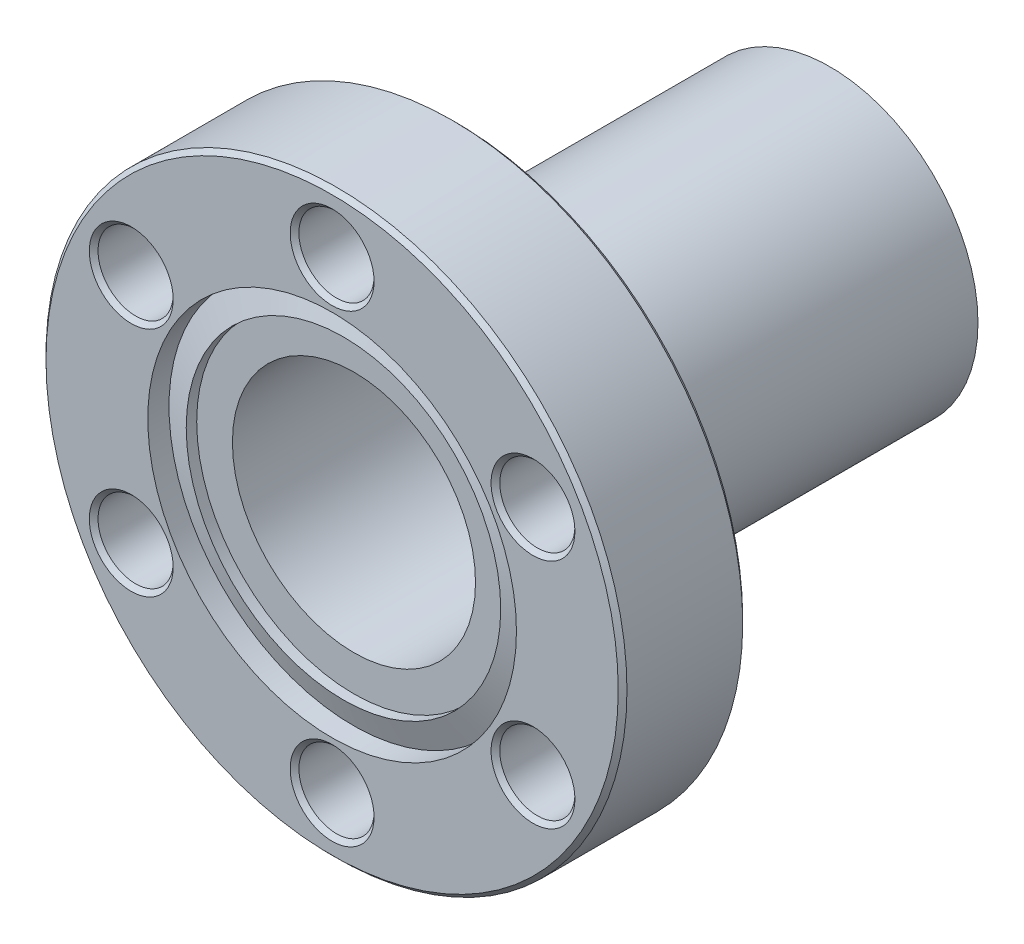
from build123d import *

# Parameters (mm, degrees)
M8_CLEARANCE_HOLE1_D     = 9.5758
M8_CLEARANCE_HOLE1_DEPTH = 7.239
M4_CLEARANCE_HOLE1_D     = 4.3688
M4_CLEARANCE_HOLE1_DEPTH = 7.239
M4_CLEARANCE_HOLE2_D     = 4.3688
M4_CLEARANCE_HOLE2_DEPTH = 7.239
CHAMFER1_SIZE            = 0.254
SKETCH8_R                = 8.600554372
BOSS_EXTRUDE1_DEPTH      = 21.717
SKETCH9_R                = 7.068084354
CUT_EXTRUDE1_DEPTH       = 29.956


with BuildPart() as part:
    # Sketch1 → Revolve1 (revolve)
    with BuildSketch(Plane(origin=(0, 0, 0), x_dir=(1, 0, 0), z_dir=(0, 1, 0))):
        with BuildLine():
            Line((16.891, 7.239), (0, 7.239))
            Line((0, 7.239), (0, 1.27))
            Line((0, 1.27), (5.321088826, 1.27))
            ThreePointArc((5.321088826, 1.27), (6.0579, 1.83769793), (6.794711174, 1.27))
            Line((6.794711174, 1.27), (9.144, 1.27))
            Line((9.144, 1.27), (9.144, 0.6604))
            Line((9.144, 0.6604), (10.7188, 1.233580325))
            Line((10.7188, 1.233580325), (10.7188, 0))
            Line((10.7188, 0), (16.891, 0))
            Line((16.891, 0), (16.891, 7.239))
        make_face()
    revolve(axis=Axis((0, 0, -7.239), (0, 0, 1)))

    # M8 Clearance Hole1
    with Locations(Plane(origin=(0, 0, -7.239), x_dir=(-1, 0, 0), z_dir=(0, 0, -1))):
        with Locations((0, 0)):
            Hole(M8_CLEARANCE_HOLE1_D / 2, depth=M8_CLEARANCE_HOLE1_DEPTH)

    # M4 Clearance Hole1
    with Locations(Plane.XY):
        with Locations((11.680431031, 6.7437), (0, -13.4874), (-11.680431031, -6.7437), (-11.680431031, 6.7437)):
            Hole(M4_CLEARANCE_HOLE1_D / 2, depth=M4_CLEARANCE_HOLE1_DEPTH)

    # M4 Clearance Hole2
    with Locations(Plane(origin=(0, 0, -7.239), x_dir=(-1, 0, 0), z_dir=(0, 0, -1))):
        with Locations((0, 13.4874), (-11.680431031, -6.7437)):
            Hole(M4_CLEARANCE_HOLE2_D / 2, depth=M4_CLEARANCE_HOLE2_DEPTH)

    # Chamfer1
    chamfer1_edges = [part.edges().sort_by_distance(p)[0] for p in [
        (-16.891, 0, 0),
        (-9.496031031, 6.7437, 0),
        (-9.496031031, 6.7437, -7.239),
        (-9.496031031, -6.7437, 0),
        (-9.496031031, -6.7437, -7.239),
        (2.1844, -13.4874, 0),
        (2.1844, -13.4874, -7.239),
        (13.864831031, 6.7437, 0),
        (13.864831031, 6.7437, -7.239),
        (9.496031031, -6.7437, -7.239),
        (9.496031031, -6.7437, 0),
        (-2.1844, 13.4874, -7.239),
        (-2.1844, 13.4874, 0),
        (-16.891, 0, -7.239),
    ]]
    chamfer(chamfer1_edges, length=CHAMFER1_SIZE)

    # Sketch8 → Boss-Extrude1 (add)
    with BuildSketch(Plane(origin=(0, 0, -7.239), x_dir=(-1, 0, 0), z_dir=(0, 0, -1))):
        Circle(SKETCH8_R)
    extrude(amount=BOSS_EXTRUDE1_DEPTH)

    # Sketch9 → Cut-Extrude1 (cut, through all)
    with BuildSketch(Plane(origin=(0, 0, -28.956), x_dir=(-1, 0, 0), z_dir=(0, 0, -1))):
        Circle(SKETCH9_R)
    extrude(amount=-CUT_EXTRUDE1_DEPTH, mode=Mode.SUBTRACT)


solid = part.part
